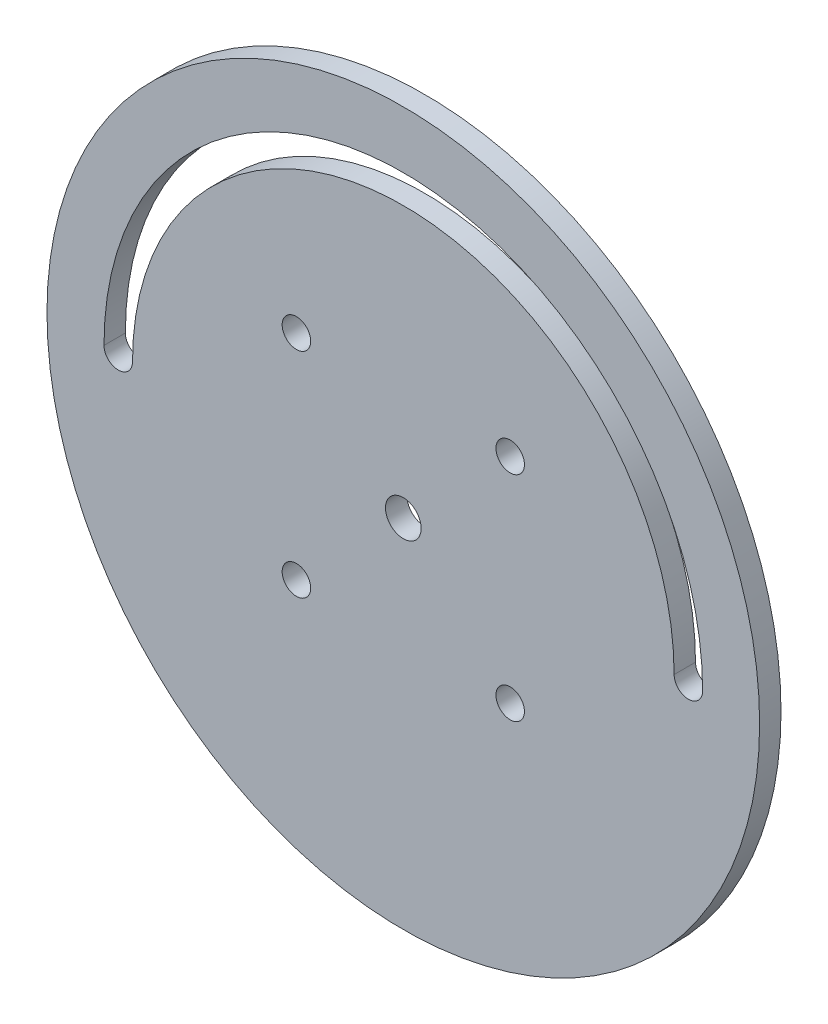
from build123d import *

# Parameters (mm, degrees)
SKETCH1_R           = 50
SKETCH1_R_2         = 2.5
BOSS_EXTRUDE1_DEPTH = 3
SKETCH2_R           = 2
CUT_EXTRUDE1_DEPTH  = 4


with BuildPart() as part:
    # Sketch1 → Boss-Extrude1 (new body)
    with BuildSketch(Plane.XY):
        Circle(SKETCH1_R)
        Circle(SKETCH1_R_2, mode=Mode.SUBTRACT)
        with BuildLine():
            ThreePointArc((42, 0), (0, 42), (-42, 0))
            ThreePointArc((-42, 0), (-40, -2), (-38, 0))
            ThreePointArc((-38, 0), (0, 38), (38, 0))
            ThreePointArc((38, 0), (40, -2), (42, 0))
        make_face(mode=Mode.SUBTRACT)
    extrude(amount=BOSS_EXTRUDE1_DEPTH)

    # Sketch2 → Cut-Extrude1 (cut, through all)
    with BuildSketch(Plane.XY.offset(3)):
        with Locations((-15, 15)):
            Circle(SKETCH2_R)
        with Locations((15, 15)):
            Circle(SKETCH2_R)
        with Locations((15, -15)):
            Circle(SKETCH2_R)
        with Locations((-15, -15)):
            Circle(SKETCH2_R)
    extrude(amount=-CUT_EXTRUDE1_DEPTH, mode=Mode.SUBTRACT)


solid = part.part
